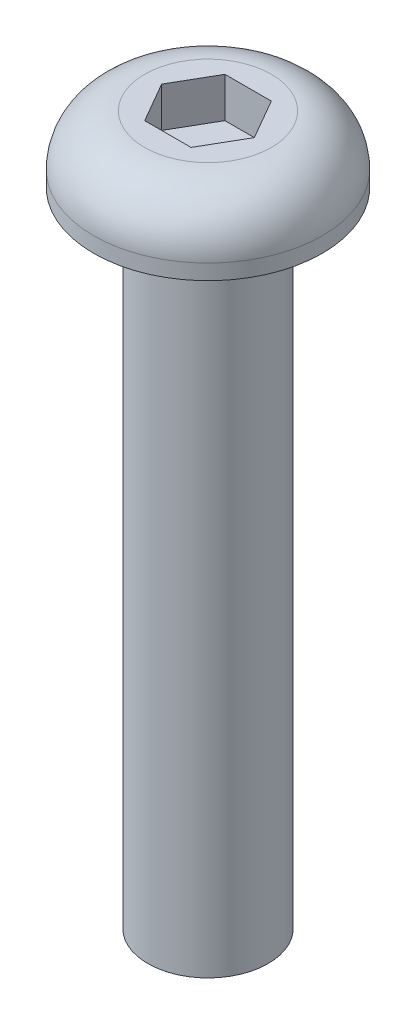
from build123d import *

# Parameters (mm, degrees)
CUT_EXTRUDE1_DEPTH = 1


with BuildPart() as part:
    # Sketch1 → Revolve1 (revolve)
    with BuildSketch(Plane.XY):
        with BuildLine():
            Line((1.5, 0), (2.85, 0))
            Line((2.85, 0), (2.85, 0.38))
            ThreePointArc((2.85, 0.38), (2.478025612, 1.278025612), (1.58, 1.65))
            Line((1.58, 1.65), (0, 1.65))
            Line((0, 1.65), (0, -16))
            Line((0, -16), (1.5, -16))
            Line((1.5, -16), (1.5, 0))
        make_face()
    revolve(axis=Axis((0, -16, 0), (0, 1, 0)))

    # Sketch2 → Cut-Extrude1 (cut)
    with BuildSketch(Plane(origin=(0, 1.65, 0), x_dir=(1, 0, 0), z_dir=(0, 1, 0))):
        Polygon((0.577350269, 1), (-0.577350269, 1), (-1.154700538, 0), (-0.577350269, -1), (0.577350269, -1), (1.154700538, 0), align=None)
    extrude(amount=-CUT_EXTRUDE1_DEPTH, mode=Mode.SUBTRACT)


solid = part.part
